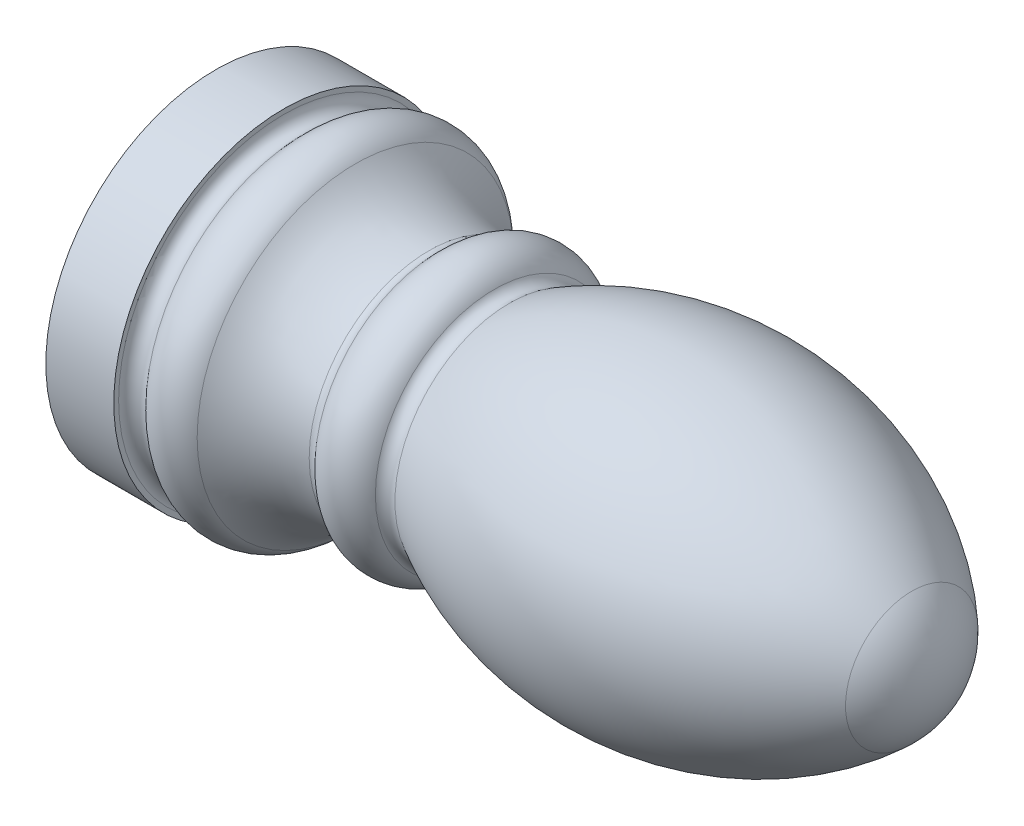
from build123d import *


with BuildPart() as part:
    # Sketch1 → Revolve1 (revolve)
    with BuildSketch(Plane.XY):
        with BuildLine():
            Line((0, 0), (0, -7.5))
            Line((0, -7.5), (3, -7.5))
            Line((3, -7.5), (3, -7.285575219))
            ThreePointArc((3, -7.285575219), (3.328989928, -6.815728909), (3.883022222, -6.964181415))
            ThreePointArc((3.883022222, -6.964181415), (5.019570731, -7.499947764), (6.164903024, -6.98322537))
            ThreePointArc((6.164903024, -6.98322537), (7.629198824, -5.827156404), (9.415351221, -5.288345436))
            ThreePointArc((9.415351221, -5.288345436), (9.655076577, -5.321927627), (9.850933335, -5.464181415))
            ThreePointArc((9.850933335, -5.464181415), (11.130733614, -5.994292047), (12.299038106, -5.25))
            ThreePointArc((12.299038106, -5.25), (12.599604254, -5.017861109), (12.97658066, -5.063874845))
            ThreePointArc((12.97658066, -5.063874845), (22.202032886, -6.891114213), (30.729179265, -2.924308558))
            ThreePointArc((30.729179265, -2.924308558), (31.668563551, -1.594252637), (32, 0))
            Line((32, 0), (0, 0))
        make_face()
    revolve(axis=Axis((0, 0, 0), (-1, 0, 0)))


solid = part.part
